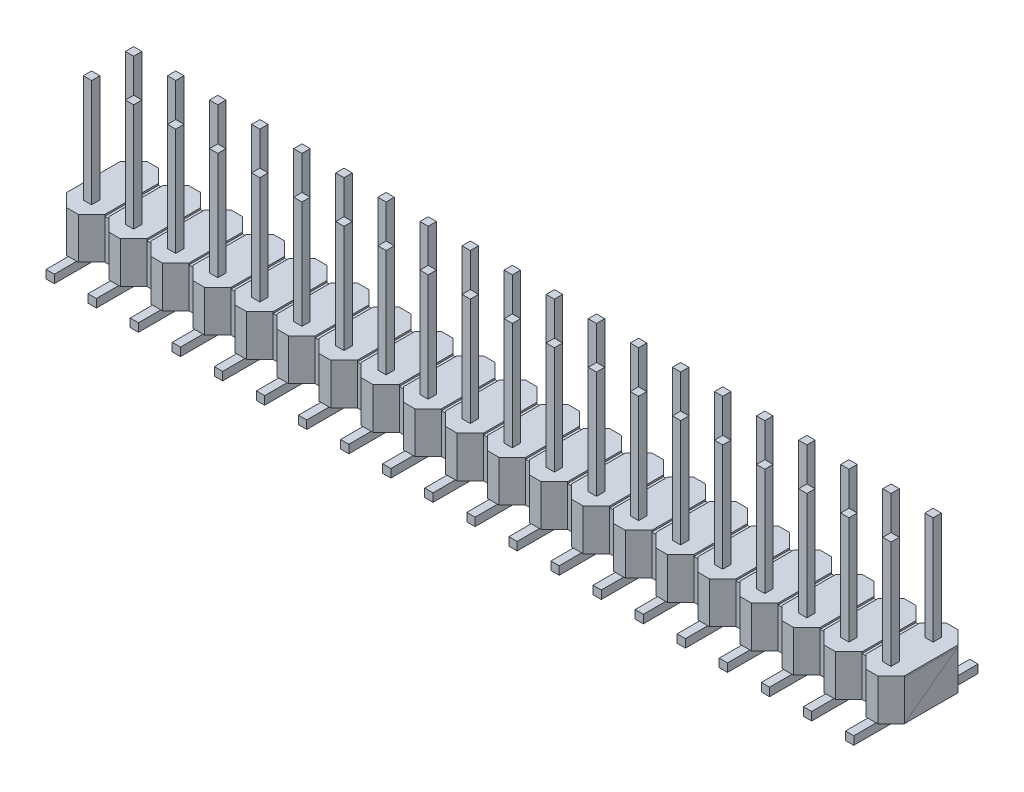
from build123d import *

# Parameters (mm, degrees)
CROQUIS1_W        = 0.5
CROQUIS1_H        = 0.5
EXTRUIR1_DEPTH    = 9.5
CROQUIS2_W        = 0.5
CROQUIS2_H        = 7.5
EXTRUIR2_DEPTH    = 0.5
CROQUIS3_W        = 0.5
CROQUIS3_H        = 0.5
EXTRUIR4_DEPTH    = 2.5
EXTRUIR4_2_DEPTH  = 2.5
EXTRUIR4_3_DEPTH  = 2.5
EXTRUIR4_4_DEPTH  = 2.5
EXTRUIR4_5_DEPTH  = 2.5
EXTRUIR4_6_DEPTH  = 2.5
EXTRUIR4_7_DEPTH  = 2.5
EXTRUIR4_8_DEPTH  = 2.5
EXTRUIR4_9_DEPTH  = 2.5
EXTRUIR4_10_DEPTH = 2.5
EXTRUIR4_11_DEPTH = 2.5
EXTRUIR4_12_DEPTH = 2.5
EXTRUIR4_13_DEPTH = 2.5
EXTRUIR4_14_DEPTH = 2.5
EXTRUIR4_15_DEPTH = 2.5
EXTRUIR4_16_DEPTH = 2.5
EXTRUIR4_17_DEPTH = 2.5
EXTRUIR4_18_DEPTH = 2.5
EXTRUIR4_19_DEPTH = 2.5
EXTRUIR4_20_DEPTH = 2.5
CROQUIS4_W        = 50.56
CROQUIS4_H        = 3.24
EXTRUIR5_DEPTH    = 2.4


with BuildPart() as part:
    # Croquis1 → Extruir1 (new body)
    with BuildSketch(Plane(origin=(0, 0, 0), x_dir=(1, 0, 0), z_dir=(0, 1, 0))):
        with Locations((2.79, 0.25)):
            Rectangle(CROQUIS1_W, CROQUIS1_H)
        with Locations((0.25, 0.25)):
            Rectangle(CROQUIS1_W, CROQUIS1_H)
        with Locations((5.33, 0.25)):
            Rectangle(CROQUIS1_W, CROQUIS1_H)
        with Locations((7.87, 0.25)):
            Rectangle(CROQUIS1_W, CROQUIS1_H)
        with Locations((10.41, 0.25)):
            Rectangle(CROQUIS1_W, CROQUIS1_H)
        with Locations((12.95, 0.25)):
            Rectangle(CROQUIS1_W, CROQUIS1_H)
        with Locations((15.49, 0.25)):
            Rectangle(CROQUIS1_W, CROQUIS1_H)
        with Locations((18.03, 0.25)):
            Rectangle(CROQUIS1_W, CROQUIS1_H)
        with Locations((20.57, 0.25)):
            Rectangle(CROQUIS1_W, CROQUIS1_H)
        with Locations((23.11, 0.25)):
            Rectangle(CROQUIS1_W, CROQUIS1_H)
        with Locations((25.65, 0.25)):
            Rectangle(CROQUIS1_W, CROQUIS1_H)
        with Locations((28.19, 0.25)):
            Rectangle(CROQUIS1_W, CROQUIS1_H)
        with Locations((30.73, 0.25)):
            Rectangle(CROQUIS1_W, CROQUIS1_H)
        with Locations((33.27, 0.25)):
            Rectangle(CROQUIS1_W, CROQUIS1_H)
        with Locations((35.81, 0.25)):
            Rectangle(CROQUIS1_W, CROQUIS1_H)
        with Locations((38.35, 0.25)):
            Rectangle(CROQUIS1_W, CROQUIS1_H)
        with Locations((40.89, 0.25)):
            Rectangle(CROQUIS1_W, CROQUIS1_H)
        with Locations((43.43, 0.25)):
            Rectangle(CROQUIS1_W, CROQUIS1_H)
        with Locations((45.97, 0.25)):
            Rectangle(CROQUIS1_W, CROQUIS1_H)
        with Locations((48.51, 0.25)):
            Rectangle(CROQUIS1_W, CROQUIS1_H)
        with Locations((0.25, 2.79)):
            Rectangle(CROQUIS1_W, CROQUIS1_H)
        with Locations((2.79, 2.79)):
            Rectangle(CROQUIS1_W, CROQUIS1_H)
        with Locations((5.33, 2.79)):
            Rectangle(CROQUIS1_W, CROQUIS1_H)
        with Locations((7.87, 2.79)):
            Rectangle(CROQUIS1_W, CROQUIS1_H)
        with Locations((10.41, 2.79)):
            Rectangle(CROQUIS1_W, CROQUIS1_H)
        with Locations((12.95, 2.79)):
            Rectangle(CROQUIS1_W, CROQUIS1_H)
        with Locations((15.49, 2.79)):
            Rectangle(CROQUIS1_W, CROQUIS1_H)
        with Locations((18.03, 2.79)):
            Rectangle(CROQUIS1_W, CROQUIS1_H)
        with Locations((20.57, 2.79)):
            Rectangle(CROQUIS1_W, CROQUIS1_H)
        with Locations((23.11, 2.79)):
            Rectangle(CROQUIS1_W, CROQUIS1_H)
        with Locations((25.65, 2.79)):
            Rectangle(CROQUIS1_W, CROQUIS1_H)
        with Locations((28.19, 2.79)):
            Rectangle(CROQUIS1_W, CROQUIS1_H)
        with Locations((30.73, 2.79)):
            Rectangle(CROQUIS1_W, CROQUIS1_H)
        with Locations((33.27, 2.79)):
            Rectangle(CROQUIS1_W, CROQUIS1_H)
        with Locations((35.81, 2.79)):
            Rectangle(CROQUIS1_W, CROQUIS1_H)
        with Locations((38.35, 2.79)):
            Rectangle(CROQUIS1_W, CROQUIS1_H)
        with Locations((40.89, 2.79)):
            Rectangle(CROQUIS1_W, CROQUIS1_H)
        with Locations((43.43, 2.79)):
            Rectangle(CROQUIS1_W, CROQUIS1_H)
        with Locations((45.97, 2.79)):
            Rectangle(CROQUIS1_W, CROQUIS1_H)
        with Locations((48.51, 2.79)):
            Rectangle(CROQUIS1_W, CROQUIS1_H)
    extrude(amount=EXTRUIR1_DEPTH)

    # Croquis2 → Extruir2 (add)
    with BuildSketch(Plane.XZ):
        with Locations((2.79, -1.5)):
            Rectangle(CROQUIS2_W, CROQUIS2_H)
        with Locations((0.25, -1.5)):
            Rectangle(CROQUIS2_W, CROQUIS2_H)
        with Locations((5.33, -1.5)):
            Rectangle(CROQUIS2_W, CROQUIS2_H)
        with Locations((7.87, -1.5)):
            Rectangle(CROQUIS2_W, CROQUIS2_H)
        with Locations((10.41, -1.5)):
            Rectangle(CROQUIS2_W, CROQUIS2_H)
        with Locations((12.95, -1.5)):
            Rectangle(CROQUIS2_W, CROQUIS2_H)
        with Locations((15.49, -1.5)):
            Rectangle(CROQUIS2_W, CROQUIS2_H)
        with Locations((18.03, -1.5)):
            Rectangle(CROQUIS2_W, CROQUIS2_H)
        with Locations((20.57, -1.5)):
            Rectangle(CROQUIS2_W, CROQUIS2_H)
        with Locations((23.11, -1.5)):
            Rectangle(CROQUIS2_W, CROQUIS2_H)
        with Locations((25.65, -1.5)):
            Rectangle(CROQUIS2_W, CROQUIS2_H)
        with Locations((28.19, -1.5)):
            Rectangle(CROQUIS2_W, CROQUIS2_H)
        with Locations((30.73, -1.5)):
            Rectangle(CROQUIS2_W, CROQUIS2_H)
        with Locations((33.27, -1.5)):
            Rectangle(CROQUIS2_W, CROQUIS2_H)
        with Locations((35.81, -1.5)):
            Rectangle(CROQUIS2_W, CROQUIS2_H)
        with Locations((38.35, -1.5)):
            Rectangle(CROQUIS2_W, CROQUIS2_H)
        with Locations((40.89, -1.5)):
            Rectangle(CROQUIS2_W, CROQUIS2_H)
        with Locations((43.43, -1.5)):
            Rectangle(CROQUIS2_W, CROQUIS2_H)
        with Locations((45.97, -1.5)):
            Rectangle(CROQUIS2_W, CROQUIS2_H)
        with Locations((48.51, -1.5)):
            Rectangle(CROQUIS2_W, CROQUIS2_H)
    extrude(amount=-EXTRUIR2_DEPTH)


with BuildPart() as body_2:
    # Croquis3 → Extruir4 (new body)
    with BuildSketch(Plane(origin=(0, 0.5, 0), x_dir=(-1, 0, 0), z_dir=(0, 1, 0))):
        Polygon((-0.6, -3.94), (0.1, -3.94), (0.9, -3.14), (0.9, 0.1), (0.1, 0.9), (-0.6, 0.9), (-1.4, 0.1), (-1.4, -3.14), align=None)
        with Locations((-0.25, -2.79)):
            Rectangle(CROQUIS3_W, CROQUIS3_H, mode=Mode.SUBTRACT)
        with Locations((-0.25, -0.25)):
            Rectangle(CROQUIS3_W, CROQUIS3_H, mode=Mode.SUBTRACT)
    extrude(amount=EXTRUIR4_DEPTH)


with BuildPart() as body_3:
    # Croquis3 → Extruir4 2 (new body)
    with BuildSketch(Plane(origin=(0, 0.5, 0), x_dir=(-1, 0, 0), z_dir=(0, 1, 0))):
        Polygon((-3.14, -3.94), (-2.44, -3.94), (-1.64, -3.14), (-1.64, 0.1), (-2.44, 0.9), (-3.14, 0.9), (-3.94, 0.1), (-3.94, -3.14), align=None)
        with Locations((-2.79, -2.79)):
            Rectangle(CROQUIS3_W, CROQUIS3_H, mode=Mode.SUBTRACT)
        with Locations((-2.79, -0.25)):
            Rectangle(CROQUIS3_W, CROQUIS3_H, mode=Mode.SUBTRACT)
    extrude(amount=EXTRUIR4_2_DEPTH)


with BuildPart() as body_4:
    # Croquis3 → Extruir4 3 (new body)
    with BuildSketch(Plane(origin=(0, 0.5, 0), x_dir=(-1, 0, 0), z_dir=(0, 1, 0))):
        Polygon((-5.68, -3.94), (-4.98, -3.94), (-4.18, -3.14), (-4.18, 0.1), (-4.98, 0.9), (-5.68, 0.9), (-6.48, 0.1), (-6.48, -3.14), align=None)
        with Locations((-5.33, -2.79)):
            Rectangle(CROQUIS3_W, CROQUIS3_H, mode=Mode.SUBTRACT)
        with Locations((-5.33, -0.25)):
            Rectangle(CROQUIS3_W, CROQUIS3_H, mode=Mode.SUBTRACT)
    extrude(amount=EXTRUIR4_3_DEPTH)


with BuildPart() as body_5:
    # Croquis3 → Extruir4 4 (new body)
    with BuildSketch(Plane(origin=(0, 0.5, 0), x_dir=(-1, 0, 0), z_dir=(0, 1, 0))):
        Polygon((-8.22, -3.94), (-7.52, -3.94), (-6.72, -3.14), (-6.72, 0.1), (-7.52, 0.9), (-8.22, 0.9), (-9.02, 0.1), (-9.02, -3.14), align=None)
        with Locations((-7.87, -2.79)):
            Rectangle(CROQUIS3_W, CROQUIS3_H, mode=Mode.SUBTRACT)
        with Locations((-7.87, -0.25)):
            Rectangle(CROQUIS3_W, CROQUIS3_H, mode=Mode.SUBTRACT)
    extrude(amount=EXTRUIR4_4_DEPTH)


with BuildPart() as body_6:
    # Croquis3 → Extruir4 5 (new body)
    with BuildSketch(Plane(origin=(0, 0.5, 0), x_dir=(-1, 0, 0), z_dir=(0, 1, 0))):
        Polygon((-10.76, -3.94), (-10.06, -3.94), (-9.26, -3.14), (-9.26, 0.1), (-10.06, 0.9), (-10.76, 0.9), (-11.56, 0.1), (-11.56, -3.14), align=None)
        with Locations((-10.41, -2.79)):
            Rectangle(CROQUIS3_W, CROQUIS3_H, mode=Mode.SUBTRACT)
        with Locations((-10.41, -0.25)):
            Rectangle(CROQUIS3_W, CROQUIS3_H, mode=Mode.SUBTRACT)
    extrude(amount=EXTRUIR4_5_DEPTH)


with BuildPart() as body_7:
    # Croquis3 → Extruir4 6 (new body)
    with BuildSketch(Plane(origin=(0, 0.5, 0), x_dir=(-1, 0, 0), z_dir=(0, 1, 0))):
        Polygon((-13.3, -3.94), (-12.6, -3.94), (-11.8, -3.14), (-11.8, 0.1), (-12.6, 0.9), (-13.3, 0.9), (-14.1, 0.1), (-14.1, -3.14), align=None)
        with Locations((-12.95, -2.79)):
            Rectangle(CROQUIS3_W, CROQUIS3_H, mode=Mode.SUBTRACT)
        with Locations((-12.95, -0.25)):
            Rectangle(CROQUIS3_W, CROQUIS3_H, mode=Mode.SUBTRACT)
    extrude(amount=EXTRUIR4_6_DEPTH)


with BuildPart() as body_8:
    # Croquis3 → Extruir4 7 (new body)
    with BuildSketch(Plane(origin=(0, 0.5, 0), x_dir=(-1, 0, 0), z_dir=(0, 1, 0))):
        Polygon((-15.84, -3.94), (-15.14, -3.94), (-14.34, -3.14), (-14.34, 0.1), (-15.14, 0.9), (-15.84, 0.9), (-16.64, 0.1), (-16.64, -3.14), align=None)
        with Locations((-15.49, -2.79)):
            Rectangle(CROQUIS3_W, CROQUIS3_H, mode=Mode.SUBTRACT)
        with Locations((-15.49, -0.25)):
            Rectangle(CROQUIS3_W, CROQUIS3_H, mode=Mode.SUBTRACT)
    extrude(amount=EXTRUIR4_7_DEPTH)


with BuildPart() as body_9:
    # Croquis3 → Extruir4 8 (new body)
    with BuildSketch(Plane(origin=(0, 0.5, 0), x_dir=(-1, 0, 0), z_dir=(0, 1, 0))):
        Polygon((-18.38, -3.94), (-17.68, -3.94), (-16.88, -3.14), (-16.88, 0.1), (-17.68, 0.9), (-18.38, 0.9), (-19.18, 0.1), (-19.18, -3.14), align=None)
        with Locations((-18.03, -2.79)):
            Rectangle(CROQUIS3_W, CROQUIS3_H, mode=Mode.SUBTRACT)
        with Locations((-18.03, -0.25)):
            Rectangle(CROQUIS3_W, CROQUIS3_H, mode=Mode.SUBTRACT)
    extrude(amount=EXTRUIR4_8_DEPTH)


with BuildPart() as body_10:
    # Croquis3 → Extruir4 9 (new body)
    with BuildSketch(Plane(origin=(0, 0.5, 0), x_dir=(-1, 0, 0), z_dir=(0, 1, 0))):
        Polygon((-20.92, -3.94), (-20.22, -3.94), (-19.42, -3.14), (-19.42, 0.1), (-20.22, 0.9), (-20.92, 0.9), (-21.72, 0.1), (-21.72, -3.14), align=None)
        with Locations((-20.57, -2.79)):
            Rectangle(CROQUIS3_W, CROQUIS3_H, mode=Mode.SUBTRACT)
        with Locations((-20.57, -0.25)):
            Rectangle(CROQUIS3_W, CROQUIS3_H, mode=Mode.SUBTRACT)
    extrude(amount=EXTRUIR4_9_DEPTH)


with BuildPart() as body_11:
    # Croquis3 → Extruir4 10 (new body)
    with BuildSketch(Plane(origin=(0, 0.5, 0), x_dir=(-1, 0, 0), z_dir=(0, 1, 0))):
        Polygon((-23.46, -3.94), (-22.76, -3.94), (-21.96, -3.14), (-21.96, 0.1), (-22.76, 0.9), (-23.46, 0.9), (-24.26, 0.1), (-24.26, -3.14), align=None)
        with Locations((-23.11, -2.79)):
            Rectangle(CROQUIS3_W, CROQUIS3_H, mode=Mode.SUBTRACT)
        with Locations((-23.11, -0.25)):
            Rectangle(CROQUIS3_W, CROQUIS3_H, mode=Mode.SUBTRACT)
    extrude(amount=EXTRUIR4_10_DEPTH)


with BuildPart() as body_12:
    # Croquis3 → Extruir4 11 (new body)
    with BuildSketch(Plane(origin=(0, 0.5, 0), x_dir=(-1, 0, 0), z_dir=(0, 1, 0))):
        Polygon((-26, -3.94), (-25.3, -3.94), (-24.5, -3.14), (-24.5, 0.1), (-25.3, 0.9), (-26, 0.9), (-26.8, 0.1), (-26.8, -3.14), align=None)
        with Locations((-25.65, -2.79)):
            Rectangle(CROQUIS3_W, CROQUIS3_H, mode=Mode.SUBTRACT)
        with Locations((-25.65, -0.25)):
            Rectangle(CROQUIS3_W, CROQUIS3_H, mode=Mode.SUBTRACT)
    extrude(amount=EXTRUIR4_11_DEPTH)


with BuildPart() as body_13:
    # Croquis3 → Extruir4 12 (new body)
    with BuildSketch(Plane(origin=(0, 0.5, 0), x_dir=(-1, 0, 0), z_dir=(0, 1, 0))):
        Polygon((-28.54, -3.94), (-27.84, -3.94), (-27.04, -3.14), (-27.04, 0.1), (-27.84, 0.9), (-28.54, 0.9), (-29.34, 0.1), (-29.34, -3.14), align=None)
        with Locations((-28.19, -2.79)):
            Rectangle(CROQUIS3_W, CROQUIS3_H, mode=Mode.SUBTRACT)
        with Locations((-28.19, -0.25)):
            Rectangle(CROQUIS3_W, CROQUIS3_H, mode=Mode.SUBTRACT)
    extrude(amount=EXTRUIR4_12_DEPTH)


with BuildPart() as body_14:
    # Croquis3 → Extruir4 13 (new body)
    with BuildSketch(Plane(origin=(0, 0.5, 0), x_dir=(-1, 0, 0), z_dir=(0, 1, 0))):
        Polygon((-31.08, -3.94), (-30.38, -3.94), (-29.58, -3.14), (-29.58, 0.1), (-30.38, 0.9), (-31.08, 0.9), (-31.88, 0.1), (-31.88, -3.14), align=None)
        with Locations((-30.73, -2.79)):
            Rectangle(CROQUIS3_W, CROQUIS3_H, mode=Mode.SUBTRACT)
        with Locations((-30.73, -0.25)):
            Rectangle(CROQUIS3_W, CROQUIS3_H, mode=Mode.SUBTRACT)
    extrude(amount=EXTRUIR4_13_DEPTH)


with BuildPart() as body_15:
    # Croquis3 → Extruir4 14 (new body)
    with BuildSketch(Plane(origin=(0, 0.5, 0), x_dir=(-1, 0, 0), z_dir=(0, 1, 0))):
        Polygon((-33.62, -3.94), (-32.92, -3.94), (-32.12, -3.14), (-32.12, 0.1), (-32.92, 0.9), (-33.62, 0.9), (-34.42, 0.1), (-34.42, -3.14), align=None)
        with Locations((-33.27, -2.79)):
            Rectangle(CROQUIS3_W, CROQUIS3_H, mode=Mode.SUBTRACT)
        with Locations((-33.27, -0.25)):
            Rectangle(CROQUIS3_W, CROQUIS3_H, mode=Mode.SUBTRACT)
    extrude(amount=EXTRUIR4_14_DEPTH)


with BuildPart() as body_16:
    # Croquis3 → Extruir4 15 (new body)
    with BuildSketch(Plane(origin=(0, 0.5, 0), x_dir=(-1, 0, 0), z_dir=(0, 1, 0))):
        Polygon((-36.16, -3.94), (-35.46, -3.94), (-34.66, -3.14), (-34.66, 0.1), (-35.46, 0.9), (-36.16, 0.9), (-36.96, 0.1), (-36.96, -3.14), align=None)
        with Locations((-35.81, -2.79)):
            Rectangle(CROQUIS3_W, CROQUIS3_H, mode=Mode.SUBTRACT)
        with Locations((-35.81, -0.25)):
            Rectangle(CROQUIS3_W, CROQUIS3_H, mode=Mode.SUBTRACT)
    extrude(amount=EXTRUIR4_15_DEPTH)


with BuildPart() as body_17:
    # Croquis3 → Extruir4 16 (new body)
    with BuildSketch(Plane(origin=(0, 0.5, 0), x_dir=(-1, 0, 0), z_dir=(0, 1, 0))):
        Polygon((-38.7, -3.94), (-38, -3.94), (-37.2, -3.14), (-37.2, 0.1), (-38, 0.9), (-38.7, 0.9), (-39.5, 0.1), (-39.5, -3.14), align=None)
        with Locations((-38.35, -2.79)):
            Rectangle(CROQUIS3_W, CROQUIS3_H, mode=Mode.SUBTRACT)
        with Locations((-38.35, -0.25)):
            Rectangle(CROQUIS3_W, CROQUIS3_H, mode=Mode.SUBTRACT)
    extrude(amount=EXTRUIR4_16_DEPTH)


with BuildPart() as body_18:
    # Croquis3 → Extruir4 17 (new body)
    with BuildSketch(Plane(origin=(0, 0.5, 0), x_dir=(-1, 0, 0), z_dir=(0, 1, 0))):
        Polygon((-41.24, -3.94), (-40.54, -3.94), (-39.74, -3.14), (-39.74, 0.1), (-40.54, 0.9), (-41.24, 0.9), (-42.04, 0.1), (-42.04, -3.14), align=None)
        with Locations((-40.89, -2.79)):
            Rectangle(CROQUIS3_W, CROQUIS3_H, mode=Mode.SUBTRACT)
        with Locations((-40.89, -0.25)):
            Rectangle(CROQUIS3_W, CROQUIS3_H, mode=Mode.SUBTRACT)
    extrude(amount=EXTRUIR4_17_DEPTH)


with BuildPart() as body_19:
    # Croquis3 → Extruir4 18 (new body)
    with BuildSketch(Plane(origin=(0, 0.5, 0), x_dir=(-1, 0, 0), z_dir=(0, 1, 0))):
        Polygon((-43.78, -3.94), (-43.08, -3.94), (-42.28, -3.14), (-42.28, 0.1), (-43.08, 0.9), (-43.78, 0.9), (-44.58, 0.1), (-44.58, -3.14), align=None)
        with Locations((-43.43, -2.79)):
            Rectangle(CROQUIS3_W, CROQUIS3_H, mode=Mode.SUBTRACT)
        with Locations((-43.43, -0.25)):
            Rectangle(CROQUIS3_W, CROQUIS3_H, mode=Mode.SUBTRACT)
    extrude(amount=EXTRUIR4_18_DEPTH)


with BuildPart() as body_20:
    # Croquis3 → Extruir4 19 (new body)
    with BuildSketch(Plane(origin=(0, 0.5, 0), x_dir=(-1, 0, 0), z_dir=(0, 1, 0))):
        Polygon((-46.32, -3.94), (-45.62, -3.94), (-44.82, -3.14), (-44.82, 0.1), (-45.62, 0.9), (-46.32, 0.9), (-47.12, 0.1), (-47.12, -3.14), align=None)
        with Locations((-45.97, -2.79)):
            Rectangle(CROQUIS3_W, CROQUIS3_H, mode=Mode.SUBTRACT)
        with Locations((-45.97, -0.25)):
            Rectangle(CROQUIS3_W, CROQUIS3_H, mode=Mode.SUBTRACT)
    extrude(amount=EXTRUIR4_19_DEPTH)


with BuildPart() as body_21:
    # Croquis3 → Extruir4 20 (new body)
    with BuildSketch(Plane(origin=(0, 0.5, 0), x_dir=(-1, 0, 0), z_dir=(0, 1, 0))):
        Polygon((-48.86, -3.94), (-48.16, -3.94), (-47.36, -3.14), (-47.36, 0.1), (-48.16, 0.9), (-48.86, 0.9), (-49.66, 0.1), (-49.66, -3.14), align=None)
        with Locations((-48.51, -2.79)):
            Rectangle(CROQUIS3_W, CROQUIS3_H, mode=Mode.SUBTRACT)
        with Locations((-48.51, -0.25)):
            Rectangle(CROQUIS3_W, CROQUIS3_H, mode=Mode.SUBTRACT)
    extrude(amount=EXTRUIR4_20_DEPTH)


with BuildPart() as body_22:
    # Croquis4 → Extruir5 (new body)
    with BuildSketch(Plane.XZ.offset(-0.5)):
        with Locations((24.38, -1.52)):
            Rectangle(CROQUIS4_W, CROQUIS4_H)
    extrude(amount=-EXTRUIR5_DEPTH)


solid = Compound([part.part, body_2.part, body_3.part, body_4.part, body_5.part, body_6.part, body_7.part, body_8.part, body_9.part, body_10.part, body_11.part, body_12.part, body_13.part, body_14.part, body_15.part, body_16.part, body_17.part, body_18.part, body_19.part, body_20.part, body_21.part, body_22.part])
